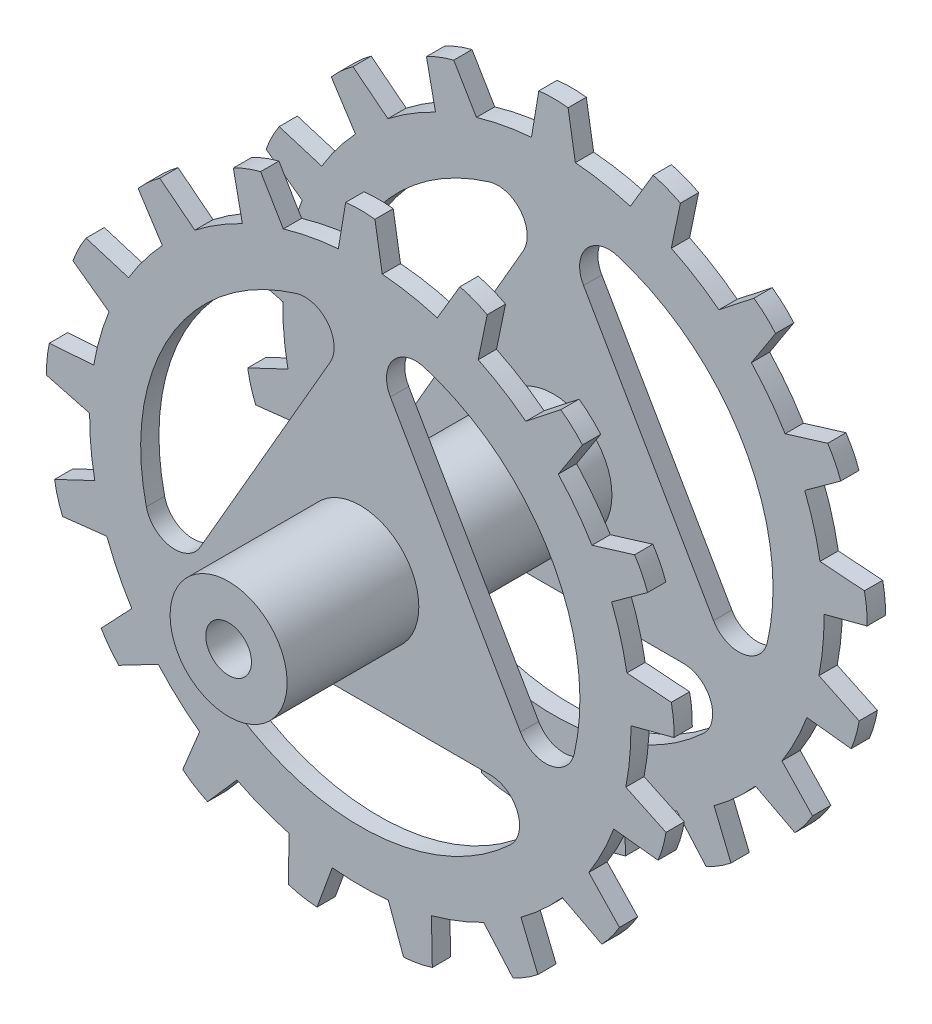
from build123d import *

# Parameters (mm, degrees)
BOSS_EXTRUDE2_START = 8.382
SKETCH2_R           = 5.08
BOSS_EXTRUDE2_DEPTH = 1.5875
BOSS_EXTRUDE3_START = -8.382
SKETCH2_3_R         = 5.08
BOSS_EXTRUDE3_DEPTH = 1.5875
SKETCH3_R           = 5.08
BOSS_EXTRUDE4_DEPTH = 29.7815
SKETCH4_R           = 1.984375
CUT_EXTRUDE2_DEPTH  = 30.7815


with BuildPart() as part:
    # Sketch2 → Boss-Extrude2 (new body)
    with BuildSketch(Plane.XY.offset(BOSS_EXTRUDE2_START)):
        with BuildLine():
            Line((-1.27, 27.227642922), (-1.905, 23.417642922))
            ThreePointArc((-1.905, 23.417642922), (-4.317194921, 23.094952977), (-6.68306875, 22.524467077))
            Line((-6.68306875, 22.524467077), (-8.651519364, 25.847797813))
            ThreePointArc((-8.651519364, 25.847797813), (-9.863703695, 25.461154224), (-11.019998827, 24.93024398))
            Line((-11.019998827, 24.93024398), (-10.235787944, 21.148136328))
            ThreePointArc((-10.235787944, 21.148136328), (-12.368523667, 19.975851604), (-14.368552033, 18.58923714))
            Line((-14.368552033, 18.58923714), (-17.404603098, 20.977064381))
            ThreePointArc((-17.404603098, 20.977064381), (-18.39525955, 20.178638485), (-19.281685748, 19.265877446))
            Line((-19.281685748, 19.265877446), (-17.184176008, 16.022456738))
            ThreePointArc((-17.184176008, 16.022456738), (-18.749414755, 14.158900782), (-20.113482746, 12.143427722))
            Line((-20.113482746, 12.143427722), (-23.807098742, 13.273262168))
            ThreePointArc((-23.807098742, 13.273262168), (-24.44243367, 12.170885804), (-24.939274165, 10.999547407))
            Line((-24.939274165, 10.999547407), (-21.811745881, 8.732855582))
            ThreePointArc((-21.811745881, 8.732855582), (-22.598093486, 6.429711952), (-23.14197616, 4.057581101))
            Line((-23.14197616, 4.057581101), (-26.99431378, 3.776832348))
            ThreePointArc((-26.99431378, 3.776832348), (-27.188521684, 2.519387555), (-27.228675413, 1.247667541))
            Line((-27.228675413, 1.247667541), (-23.49351861, 0.263833889))
            ThreePointArc((-23.49351861, 0.263833889), (-23.394774472, -2.167845106), (-23.045017461, -4.576264332))
            Line((-23.045017461, -4.576264332), (-26.535797162, -6.229679608))
            ThreePointArc((-26.535797162, -6.229679608), (-26.262649187, -7.472367944), (-25.840693168, -8.672716741))
            Line((-25.840693168, -8.672716741), (-22.002361468, -8.240820033))
            ThreePointArc((-22.002361468, -8.240820033), (-21.03186153, -10.472622669), (-19.835701456, -12.592059909))
            Line((-19.835701456, -12.592059909), (-22.493474098, -15.394838813))
            ThreePointArc((-22.493474098, -15.394838813), (-21.789860391, -16.454938746), (-20.962782121, -17.42180257))
            Line((-20.962782121, -17.42180257), (-17.539663491, -15.632505545))
            ThreePointArc((-17.539663491, -15.632505545), (-15.828479147, -17.36301451), (-13.947464056, -18.90722802))
            Line((-13.947464056, -18.90722802), (-15.413282716, -22.480839731))
            ThreePointArc((-15.413282716, -22.480839731), (-14.374230207, -23.215178891), (-13.253731191, -23.817977424))
            Line((-13.253731191, -23.817977424), (-10.708136769, -20.912934561))
            ThreePointArc((-10.708136769, -20.912934561), (-8.487372947, -21.90843503), (-6.17554435, -22.668870218))
            Line((-6.17554435, -22.668870218), (-6.251442095, -26.530678672))
            ThreePointArc((-6.251442095, -26.530678672), (-5.017280584, -26.840080487), (-3.754690422, -26.997402447))
            Line((-3.754690422, -26.997402447), (-2.43041684, -23.368955881))
            ThreePointArc((-2.43041684, -23.368955881), (0, -23.495), (2.43041684, -23.368955881))
            Line((2.43041684, -23.368955881), (3.754690422, -26.997402447))
            ThreePointArc((3.754690422, -26.997402447), (5.017280584, -26.840080487), (6.251442095, -26.530678672))
            Line((6.251442095, -26.530678672), (6.17554435, -22.668870218))
            ThreePointArc((6.17554435, -22.668870218), (8.487372947, -21.90843503), (10.708136769, -20.912934561))
            Line((10.708136769, -20.912934561), (13.253731191, -23.817977424))
            ThreePointArc((13.253731191, -23.817977424), (14.374230207, -23.215178891), (15.413282716, -22.480839731))
            Line((15.413282716, -22.480839731), (13.947464056, -18.90722802))
            ThreePointArc((13.947464056, -18.90722802), (15.828479147, -17.36301451), (17.539663491, -15.632505545))
            Line((17.539663491, -15.632505545), (20.962782121, -17.42180257))
            ThreePointArc((20.962782121, -17.42180257), (21.789860391, -16.454938746), (22.493474098, -15.394838813))
            Line((22.493474098, -15.394838813), (19.835701456, -12.592059909))
            ThreePointArc((19.835701456, -12.592059909), (21.03186153, -10.472622669), (22.002361468, -8.240820033))
            Line((22.002361468, -8.240820033), (25.840693168, -8.672716741))
            ThreePointArc((25.840693168, -8.672716741), (26.262649187, -7.472367944), (26.535797162, -6.229679608))
            Line((26.535797162, -6.229679608), (23.045017461, -4.576264332))
            ThreePointArc((23.045017461, -4.576264332), (23.394774472, -2.167845106), (23.49351861, 0.263833889))
            Line((23.49351861, 0.263833889), (27.228675413, 1.247667541))
            ThreePointArc((27.228675413, 1.247667541), (27.188521684, 2.519387555), (26.99431378, 3.776832348))
            Line((26.99431378, 3.776832348), (23.14197616, 4.057581101))
            ThreePointArc((23.14197616, 4.057581101), (22.598093486, 6.429711952), (21.811745881, 8.732855582))
            Line((21.811745881, 8.732855582), (24.939274165, 10.999547407))
            ThreePointArc((24.939274165, 10.999547407), (24.44243367, 12.170885804), (23.807098742, 13.273262168))
            Line((23.807098742, 13.273262168), (20.113482746, 12.143427722))
            ThreePointArc((20.113482746, 12.143427722), (18.749414755, 14.158900782), (17.184176008, 16.022456738))
            Line((17.184176008, 16.022456738), (19.281685748, 19.265877446))
            ThreePointArc((19.281685748, 19.265877446), (18.39525955, 20.178638485), (17.404603098, 20.977064381))
            Line((17.404603098, 20.977064381), (14.368552033, 18.58923714))
            ThreePointArc((14.368552033, 18.58923714), (12.368523667, 19.975851604), (10.235787944, 21.148136328))
            Line((10.235787944, 21.148136328), (11.019998827, 24.93024398))
            ThreePointArc((11.019998827, 24.93024398), (9.863703695, 25.461154224), (8.651519364, 25.847797813))
            Line((8.651519364, 25.847797813), (6.68306875, 22.524467077))
            ThreePointArc((6.68306875, 22.524467077), (4.317194921, 23.094952977), (1.905, 23.417642922))
            Line((1.905, 23.417642922), (1.27, 27.227642922))
            ThreePointArc((1.27, 27.227642922), (0, 27.305), (-1.27, 27.227642922))
        make_face()
        Circle(SKETCH2_R, mode=Mode.SUBTRACT)
        with BuildLine():
            Line((-2.613377602, 14.537603103), (-13.896622398, -5.005550158))
            ThreePointArc((-13.896622398, -5.005550158), (-16.470324404, -6.247865004), (-18.570570956, -4.309759587))
            ThreePointArc((-18.570570956, -4.309759587), (-16.51, 9.532052944), (-5.552924191, 18.237466004))
            ThreePointArc((-5.552924191, 18.237466004), (-2.824352389, 17.387651844), (-2.613377602, 14.537603103))
        make_face(mode=Mode.SUBTRACT)
        with BuildLine():
            Line((13.896622398, -5.005550158), (2.613377602, 14.537603103))
            ThreePointArc((2.613377602, 14.537603103), (2.824352389, 17.387651844), (5.552924191, 18.237466004))
            ThreePointArc((5.552924191, 18.237466004), (16.51, 9.532052944), (18.570570956, -4.309759587))
            ThreePointArc((18.570570956, -4.309759587), (16.470324404, -6.247865004), (13.896622398, -5.005550158))
        make_face(mode=Mode.SUBTRACT)
        with BuildLine():
            Line((-11.283244796, -9.532052944), (11.283244796, -9.532052944))
            ThreePointArc((11.283244796, -9.532052944), (13.645972015, -11.13978684), (13.017646765, -13.927706417))
            ThreePointArc((13.017646765, -13.927706417), (0, -19.064105889), (-13.017646765, -13.927706417))
            ThreePointArc((-13.017646765, -13.927706417), (-13.645972015, -11.13978684), (-11.283244796, -9.532052944))
        make_face(mode=Mode.SUBTRACT)
    extrude(amount=BOSS_EXTRUDE2_DEPTH)



with BuildPart() as body_2:
    # Sketch2_3 → Boss-Extrude3 (new body)
    with BuildSketch(Plane.XY.offset(BOSS_EXTRUDE3_START)):
        with BuildLine():
            Line((-1.27, 27.227642922), (-1.905, 23.417642922))
            ThreePointArc((-1.905, 23.417642922), (-4.317194921, 23.094952977), (-6.68306875, 22.524467077))
            Line((-6.68306875, 22.524467077), (-8.651519364, 25.847797813))
            ThreePointArc((-8.651519364, 25.847797813), (-9.863703695, 25.461154224), (-11.019998827, 24.93024398))
            Line((-11.019998827, 24.93024398), (-10.235787944, 21.148136328))
            ThreePointArc((-10.235787944, 21.148136328), (-12.368523667, 19.975851604), (-14.368552033, 18.58923714))
            Line((-14.368552033, 18.58923714), (-17.404603098, 20.977064381))
            ThreePointArc((-17.404603098, 20.977064381), (-18.39525955, 20.178638485), (-19.281685748, 19.265877446))
            Line((-19.281685748, 19.265877446), (-17.184176008, 16.022456738))
            ThreePointArc((-17.184176008, 16.022456738), (-18.749414755, 14.158900782), (-20.113482746, 12.143427722))
            Line((-20.113482746, 12.143427722), (-23.807098742, 13.273262168))
            ThreePointArc((-23.807098742, 13.273262168), (-24.44243367, 12.170885804), (-24.939274165, 10.999547407))
            Line((-24.939274165, 10.999547407), (-21.811745881, 8.732855582))
            ThreePointArc((-21.811745881, 8.732855582), (-22.598093486, 6.429711952), (-23.14197616, 4.057581101))
            Line((-23.14197616, 4.057581101), (-26.99431378, 3.776832348))
            ThreePointArc((-26.99431378, 3.776832348), (-27.188521684, 2.519387555), (-27.228675413, 1.247667541))
            Line((-27.228675413, 1.247667541), (-23.49351861, 0.263833889))
            ThreePointArc((-23.49351861, 0.263833889), (-23.394774472, -2.167845106), (-23.045017461, -4.576264332))
            Line((-23.045017461, -4.576264332), (-26.535797162, -6.229679608))
            ThreePointArc((-26.535797162, -6.229679608), (-26.262649187, -7.472367944), (-25.840693168, -8.672716741))
            Line((-25.840693168, -8.672716741), (-22.002361468, -8.240820033))
            ThreePointArc((-22.002361468, -8.240820033), (-21.03186153, -10.472622669), (-19.835701456, -12.592059909))
            Line((-19.835701456, -12.592059909), (-22.493474098, -15.394838813))
            ThreePointArc((-22.493474098, -15.394838813), (-21.789860391, -16.454938746), (-20.962782121, -17.42180257))
            Line((-20.962782121, -17.42180257), (-17.539663491, -15.632505545))
            ThreePointArc((-17.539663491, -15.632505545), (-15.828479147, -17.36301451), (-13.947464056, -18.90722802))
            Line((-13.947464056, -18.90722802), (-15.413282716, -22.480839731))
            ThreePointArc((-15.413282716, -22.480839731), (-14.374230207, -23.215178891), (-13.253731191, -23.817977424))
            Line((-13.253731191, -23.817977424), (-10.708136769, -20.912934561))
            ThreePointArc((-10.708136769, -20.912934561), (-8.487372947, -21.90843503), (-6.17554435, -22.668870218))
            Line((-6.17554435, -22.668870218), (-6.251442095, -26.530678672))
            ThreePointArc((-6.251442095, -26.530678672), (-5.017280584, -26.840080487), (-3.754690422, -26.997402447))
            Line((-3.754690422, -26.997402447), (-2.43041684, -23.368955881))
            ThreePointArc((-2.43041684, -23.368955881), (0, -23.495), (2.43041684, -23.368955881))
            Line((2.43041684, -23.368955881), (3.754690422, -26.997402447))
            ThreePointArc((3.754690422, -26.997402447), (5.017280584, -26.840080487), (6.251442095, -26.530678672))
            Line((6.251442095, -26.530678672), (6.17554435, -22.668870218))
            ThreePointArc((6.17554435, -22.668870218), (8.487372947, -21.90843503), (10.708136769, -20.912934561))
            Line((10.708136769, -20.912934561), (13.253731191, -23.817977424))
            ThreePointArc((13.253731191, -23.817977424), (14.374230207, -23.215178891), (15.413282716, -22.480839731))
            Line((15.413282716, -22.480839731), (13.947464056, -18.90722802))
            ThreePointArc((13.947464056, -18.90722802), (15.828479147, -17.36301451), (17.539663491, -15.632505545))
            Line((17.539663491, -15.632505545), (20.962782121, -17.42180257))
            ThreePointArc((20.962782121, -17.42180257), (21.789860391, -16.454938746), (22.493474098, -15.394838813))
            Line((22.493474098, -15.394838813), (19.835701456, -12.592059909))
            ThreePointArc((19.835701456, -12.592059909), (21.03186153, -10.472622669), (22.002361468, -8.240820033))
            Line((22.002361468, -8.240820033), (25.840693168, -8.672716741))
            ThreePointArc((25.840693168, -8.672716741), (26.262649187, -7.472367944), (26.535797162, -6.229679608))
            Line((26.535797162, -6.229679608), (23.045017461, -4.576264332))
            ThreePointArc((23.045017461, -4.576264332), (23.394774472, -2.167845106), (23.49351861, 0.263833889))
            Line((23.49351861, 0.263833889), (27.228675413, 1.247667541))
            ThreePointArc((27.228675413, 1.247667541), (27.188521684, 2.519387555), (26.99431378, 3.776832348))
            Line((26.99431378, 3.776832348), (23.14197616, 4.057581101))
            ThreePointArc((23.14197616, 4.057581101), (22.598093486, 6.429711952), (21.811745881, 8.732855582))
            Line((21.811745881, 8.732855582), (24.939274165, 10.999547407))
            ThreePointArc((24.939274165, 10.999547407), (24.44243367, 12.170885804), (23.807098742, 13.273262168))
            Line((23.807098742, 13.273262168), (20.113482746, 12.143427722))
            ThreePointArc((20.113482746, 12.143427722), (18.749414755, 14.158900782), (17.184176008, 16.022456738))
            Line((17.184176008, 16.022456738), (19.281685748, 19.265877446))
            ThreePointArc((19.281685748, 19.265877446), (18.39525955, 20.178638485), (17.404603098, 20.977064381))
            Line((17.404603098, 20.977064381), (14.368552033, 18.58923714))
            ThreePointArc((14.368552033, 18.58923714), (12.368523667, 19.975851604), (10.235787944, 21.148136328))
            Line((10.235787944, 21.148136328), (11.019998827, 24.93024398))
            ThreePointArc((11.019998827, 24.93024398), (9.863703695, 25.461154224), (8.651519364, 25.847797813))
            Line((8.651519364, 25.847797813), (6.68306875, 22.524467077))
            ThreePointArc((6.68306875, 22.524467077), (4.317194921, 23.094952977), (1.905, 23.417642922))
            Line((1.905, 23.417642922), (1.27, 27.227642922))
            ThreePointArc((1.27, 27.227642922), (0, 27.305), (-1.27, 27.227642922))
        make_face()
        Circle(SKETCH2_3_R, mode=Mode.SUBTRACT)
        with BuildLine():
            Line((-2.613377602, 14.537603103), (-13.896622398, -5.005550158))
            ThreePointArc((-13.896622398, -5.005550158), (-16.470324404, -6.247865004), (-18.570570956, -4.309759587))
            ThreePointArc((-18.570570956, -4.309759587), (-16.51, 9.532052944), (-5.552924191, 18.237466004))
            ThreePointArc((-5.552924191, 18.237466004), (-2.824352389, 17.387651844), (-2.613377602, 14.537603103))
        make_face(mode=Mode.SUBTRACT)
        with BuildLine():
            Line((13.896622398, -5.005550158), (2.613377602, 14.537603103))
            ThreePointArc((2.613377602, 14.537603103), (2.824352389, 17.387651844), (5.552924191, 18.237466004))
            ThreePointArc((5.552924191, 18.237466004), (16.51, 9.532052944), (18.570570956, -4.309759587))
            ThreePointArc((18.570570956, -4.309759587), (16.470324404, -6.247865004), (13.896622398, -5.005550158))
        make_face(mode=Mode.SUBTRACT)
        with BuildLine():
            Line((-11.283244796, -9.532052944), (11.283244796, -9.532052944))
            ThreePointArc((11.283244796, -9.532052944), (13.645972015, -11.13978684), (13.017646765, -13.927706417))
            ThreePointArc((13.017646765, -13.927706417), (0, -19.064105889), (-13.017646765, -13.927706417))
            ThreePointArc((-13.017646765, -13.927706417), (-13.645972015, -11.13978684), (-11.283244796, -9.532052944))
        make_face(mode=Mode.SUBTRACT)
    extrude(amount=BOSS_EXTRUDE3_DEPTH)


with BuildPart() as part_1:
    add(part.part)

    add(body_2.part)  # Boss-Extrude4 merges body 2
    # Sketch3 → Boss-Extrude4 (add)
    with BuildSketch(Plane(origin=(0, 0, -8.382), x_dir=(-1, 0, 0), z_dir=(0, 0, -1))):
        Circle(SKETCH3_R)
    extrude(amount=-BOSS_EXTRUDE4_DEPTH)

    # Sketch4 → Cut-Extrude2 (cut, through all)
    with BuildSketch(Plane.XY.offset(21.3995)):
        Circle(SKETCH4_R)
    extrude(amount=-CUT_EXTRUDE2_DEPTH, mode=Mode.SUBTRACT)


solid = part_1.part
